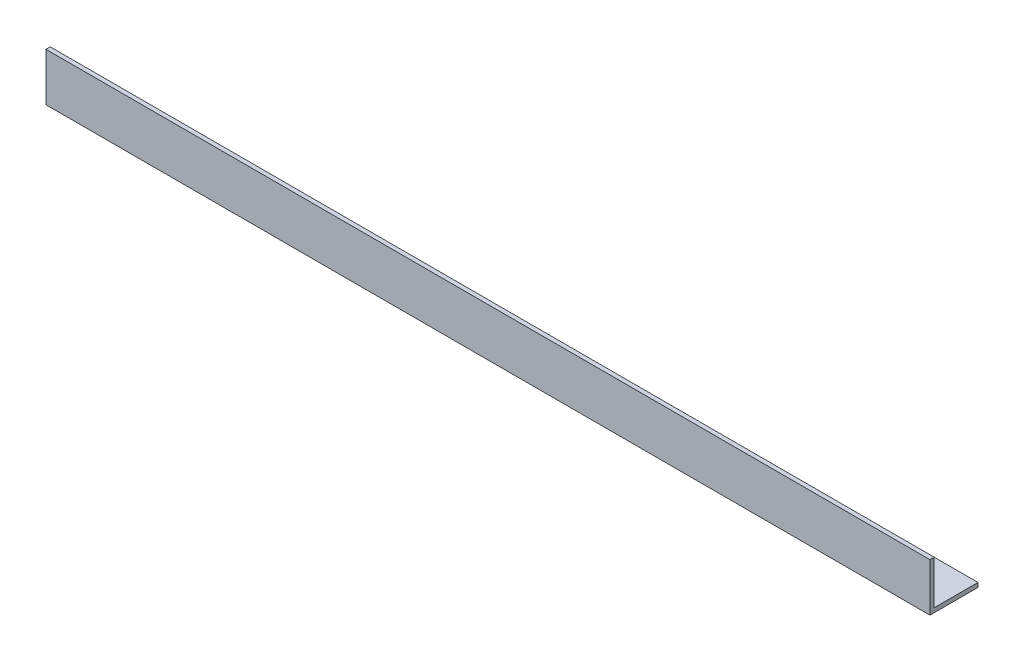
from build123d import *

# Parameters (mm, degrees)
EXTRUDE_1_DEPTH = 620


with BuildPart() as part:
    # Эскиз1 → Вытянуть-Тонкостенный1 (new body)
    with BuildSketch(Plane(origin=(0, 0, 0), x_dir=(0, 0, -1), z_dir=(1, 0, 0))):
        Polygon((0, 33.7), (0, 0), (33.7, 0), (33.7, 3), (3, 3), (3, 33.7), align=None)
    extrude(amount=EXTRUDE_1_DEPTH)


solid = part.part
